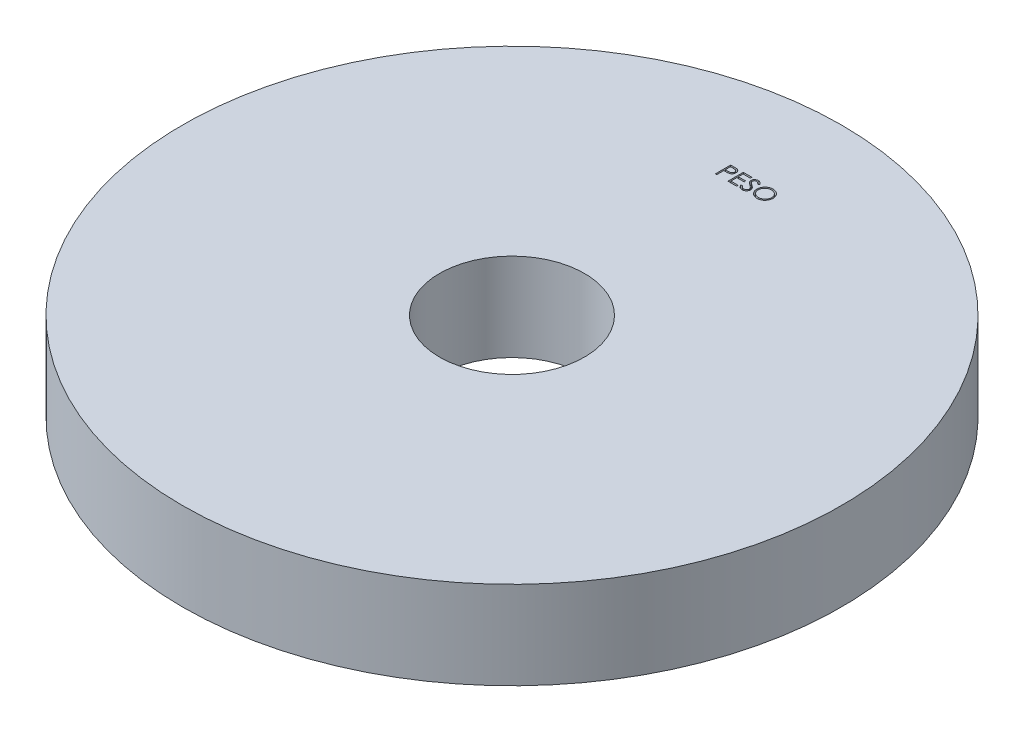
from build123d import *

# Parameters (mm, degrees)
ESBO_O1_R                = 75
ESBO_O1_R_2              = 16.5
RESSALTO_EXTRUS_O1_DEPTH = 20
CORTE_EXTRUS_O1_DEPTH    = 1


with BuildPart() as part:
    # Esboço1 → Ressalto-extrusão1 (new body)
    with BuildSketch(Plane(origin=(0, 0, 0), x_dir=(1, 0, 0), z_dir=(0, 1, 0))):
        Circle(ESBO_O1_R)
        Circle(ESBO_O1_R_2, mode=Mode.SUBTRACT)
    extrude(amount=RESSALTO_EXTRUS_O1_DEPTH)

    # Esboço2 → Corte-extrusão1 (cut)
    with BuildSketch(Plane(origin=(0, 20, 0), x_dir=(1, 0, 0), z_dir=(0, 1, 0))):
        with BuildLine():
            Line((-4.728102869, 54.494159365), (-4.041704632, 54.494159365))
            add(Edge.make_bspline(
                [(-4.041704632, 54.494159365), (-3.994493726, 54.494107469), (-3.904035533, 54.494008034), (-3.774320477, 54.490993288), (-3.656510746, 54.486966596), (-3.550860365, 54.481384703), (-3.457044267, 54.474788112), (-3.375486967, 54.465536073), (-3.305547411, 54.455875777), (-3.263640961, 54.446054371), (-3.244529151, 54.441575231)],
                knots=[0, 0, 0, 0, 0.000141628, 0.000271366, 0.00038923, 0.000495248, 0.00058876, 0.000671296, 0.000741499, 0.00080036, 0.00080036, 0.00080036, 0.00080036], degree=3))
            add(Edge.make_bspline(
                [(-3.244529151, 54.441575231), (-3.220335617, 54.434953281), (-3.17251864, 54.421865419), (-3.103617597, 54.395651696), (-3.038063752, 54.364569531), (-2.975632193, 54.329145591), (-2.91709011, 54.287860027), (-2.861564069, 54.242386409), (-2.809544089, 54.19167484), (-2.761322697, 54.1362941), (-2.717037899, 54.077173891), (-2.678908217, 54.013431661), (-2.64698099, 53.946140357), (-2.619597718, 53.875346786), (-2.599889264, 53.800456463), (-2.585042364, 53.72198975), (-2.575618736, 53.63995506), (-2.574716175, 53.583895192), (-2.574256715, 53.555357282)],
                knots=[0, 0, 0, 0, 7.5216e-05, 0.00014866, 0.000220794, 0.000292713, 0.000363707, 0.000435434, 0.000507823, 0.000581364, 0.000655543, 0.000729131, 0.000803767, 0.000878771, 0.000956497, 0.001035702, 0.001118238, 0.001203821, 0.001203821, 0.001203821, 0.001203821], degree=3))
            add(Edge.make_bspline(
                [(-2.574256715, 53.555357282), (-2.57467814, 53.526579505), (-2.575502686, 53.470273841), (-2.585398971, 53.387901053), (-2.598729163, 53.309182663), (-2.619226215, 53.234293213), (-2.646071888, 53.163677442), (-2.677563941, 53.09625621), (-2.715547472, 53.033176538), (-2.759192301, 52.974209421), (-2.807743896, 52.919299508), (-2.860996834, 52.868844714), (-2.918736126, 52.823140375), (-2.980778274, 52.782084032), (-3.047728123, 52.746627752), (-3.118570277, 52.714870447), (-3.193920493, 52.688199387), (-3.246063007, 52.674169325), (-3.272574023, 52.667035968)],
                knots=[0, 0, 0, 0, 8.6284e-05, 0.00016882, 0.000248587, 0.000325638, 0.000401297, 0.000474998, 0.000548586, 0.000621785, 0.0006948, 0.0007682, 0.000841564, 0.000915458, 0.000991056, 0.00106858, 0.00114819, 0.001230532, 0.001230532, 0.001230532, 0.001230532], degree=3))
            add(Edge.make_bspline(
                [(-3.272574023, 52.667035968), (-3.294501357, 52.662372987), (-3.342556384, 52.652153793), (-3.421699106, 52.640745336), (-3.513844492, 52.631007735), (-3.618866772, 52.623706598), (-3.736671677, 52.617456229), (-3.867322935, 52.612488135), (-4.011077012, 52.609758281), (-4.111348256, 52.609617489), (-4.163699824, 52.609543981)],
                knots=[0, 0, 0, 0, 6.7238e-05, 0.000147357, 0.000239727, 0.000345177, 0.000463135, 0.000593636, 0.000737393, 0.000894446, 0.000894446, 0.000894446, 0.000894446], degree=3))
            Line((-4.163699824, 52.609543981), (-4.414000305, 52.609543981))
            Line((-4.414000305, 52.609543981), (-4.414000305, 50.994159365))
            Line((-4.414000305, 50.994159365), (-4.728102869, 50.994159365))
            Line((-4.728102869, 50.994159365), (-4.728102869, 54.494159365))
        make_face()
        with BuildLine():
            Line((-4.414000305, 54.135185006), (-4.414000305, 52.96851834))
            Line((-4.414000305, 52.96851834), (-3.801219856, 52.960806))
            add(Edge.make_bspline(
                [(-3.801219856, 52.960806), (-3.77129993, 52.960790536), (-3.713540131, 52.960760684), (-3.630103907, 52.964745908), (-3.55269462, 52.96934644), (-3.481550045, 52.976082364), (-3.41663811, 52.985603621), (-3.357850581, 52.995215359), (-3.305643298, 53.009120722), (-3.244544097, 53.027843791), (-3.176460749, 53.059776407), (-3.102393201, 53.106126297), (-3.039622614, 53.165207005), (-2.985304317, 53.231634836), (-2.94219844, 53.305533966), (-2.910642447, 53.384602902), (-2.89210129, 53.468030752), (-2.889615096, 53.525118891), (-2.888359279, 53.553955039)],
                knots=[0, 0, 0, 0, 8.9746e-05, 0.000173253, 0.000250533, 0.00032239, 0.000387534, 0.00044736, 0.000500926, 0.000549486, 0.000638903, 0.000725641, 0.000810488, 0.000896226, 0.000982324, 0.00106604, 0.001150757, 0.001237226, 0.001237226, 0.001237226, 0.001237226], degree=3))
            add(Edge.make_bspline(
                [(-2.888359279, 53.553955039), (-2.889621926, 53.582093552), (-2.892131911, 53.638029434), (-2.910787774, 53.720008195), (-2.942137088, 53.798243899), (-2.985593682, 53.871216984), (-3.038334812, 53.937405788), (-3.099634155, 53.994902916), (-3.169347417, 54.041124618), (-3.234195648, 54.0709579), (-3.291796834, 54.089173175), (-3.341828794, 54.101918016), (-3.398319468, 54.112093622), (-3.461287248, 54.120333125), (-3.530244082, 54.127386586), (-3.605782396, 54.132172563), (-3.68761604, 54.13497402), (-3.744426611, 54.135112975), (-3.773876106, 54.135185006)],
                knots=[0, 0, 0, 0, 8.4371e-05, 0.000167719, 0.000250783, 0.000336277, 0.000421575, 0.000503926, 0.000587348, 0.000671427, 0.000717102, 0.000768457, 0.000826213, 0.000889178, 0.000958942, 0.001034123, 0.001116202, 0.001204546, 0.001204546, 0.001204546, 0.001204546], degree=3))
            Line((-3.773876106, 54.135185006), (-4.414000305, 54.135185006))
        make_face(mode=Mode.SUBTRACT)
        Polygon((-1.856307997, 54.494159365), (0.118050977, 54.494159365), (0.118050977, 54.135185006), (-1.542205433, 54.135185006), (-1.542205433, 53.05826193), (0.118050977, 53.05826193), (0.118050977, 52.699287571), (-1.542205433, 52.699287571), (-1.542205433, 51.353133724), (0.118050977, 51.353133724), (0.118050977, 50.994159365), (-1.856307997, 50.994159365), align=None)
        with BuildLine():
            Line((0.387281746, 51.669339654), (0.683155144, 51.846723468))
            add(Edge.make_bspline(
                [(0.683155144, 51.846723468), (0.710673381, 51.800659083), (0.763397262, 51.712401499), (0.851348621, 51.593143459), (0.942481532, 51.491781302), (1.037470865, 51.408904694), (1.135736814, 51.343655808), (1.237920867, 51.297453576), (1.343678678, 51.268637601), (1.4156525, 51.265137514), (1.451584631, 51.263390135)],
                knots=[0, 0, 0, 0, 0.000160901, 0.00030828, 0.000443778, 0.00056903, 0.000685513, 0.000796284, 0.00090427, 0.001011928, 0.001011928, 0.001011928, 0.001011928], degree=3))
            add(Edge.make_bspline(
                [(1.451584631, 51.263390135), (1.482271491, 51.264244807), (1.543108264, 51.265939197), (1.632670507, 51.282219999), (1.71965231, 51.307232128), (1.802260947, 51.34305306), (1.879356562, 51.386391546), (1.946963257, 51.438737723), (2.00540937, 51.497343929), (2.053218485, 51.562726584), (2.08989852, 51.633043732), (2.118090589, 51.705219683), (2.133735662, 51.780388252), (2.136092416, 51.830998715), (2.137281746, 51.856539173)],
                knots=[0, 0, 0, 0, 9.1978e-05, 0.000182347, 0.000272202, 0.000362975, 0.000451852, 0.000536835, 0.000618639, 0.000699414, 0.000778765, 0.000855983, 0.0009312, 0.001007828, 0.001007828, 0.001007828, 0.001007828], degree=3))
            add(Edge.make_bspline(
                [(2.137281746, 51.856539173), (2.135807436, 51.885680023), (2.132810377, 51.944919112), (2.107478897, 52.032318765), (2.06762965, 52.118811335), (2.030867007, 52.172312601), (2.011780945, 52.200088853)],
                knots=[0, 0, 0, 0, 8.7281e-05, 0.000177429, 0.000270909, 0.000371844, 0.000371844, 0.000371844, 0.000371844], degree=3))
            add(Edge.make_bspline(
                [(2.011780945, 52.200088853), (1.996110331, 52.220135676), (1.963211837, 52.262221475), (1.906654324, 52.32486671), (1.84028821, 52.389485129), (1.766384655, 52.458544186), (1.682251566, 52.528831983), (1.590524051, 52.603700261), (1.488860193, 52.680301838), (1.417560696, 52.731674403), (1.38077133, 52.758181801)],
                knots=[0, 0, 0, 0, 7.6319e-05, 0.000160223, 0.000252933, 0.000354147, 0.000463581, 0.000581729, 0.000709336, 0.000845369, 0.000845369, 0.000845369, 0.000845369], degree=3))
            add(Edge.make_bspline(
                [(1.38077133, 52.758181801), (1.343947333, 52.784410389), (1.273542657, 52.834557451), (1.175084075, 52.908981735), (1.087039612, 52.977025605), (1.009800595, 53.039329617), (0.943400998, 53.095902222), (0.887317587, 53.146200161), (0.84297903, 53.191583722), (0.818323449, 53.221025063), (0.807253701, 53.2342435)],
                knots=[0, 0, 0, 0, 0.000135623, 0.000259301, 0.000370234, 0.000469439, 0.00055697, 0.000631911, 0.000695377, 0.00074709, 0.00074709, 0.00074709, 0.00074709], degree=3))
            add(Edge.make_bspline(
                [(0.807253701, 53.2342435), (0.791781156, 53.254844537), (0.761352319, 53.295359241), (0.721186314, 53.358684098), (0.687047151, 53.423507364), (0.660284819, 53.490003228), (0.6377486, 53.557238157), (0.62259067, 53.626089403), (0.613099273, 53.696248021), (0.612127286, 53.743461522), (0.611640721, 53.767096064)],
                knots=[0, 0, 0, 0, 7.727e-05, 0.000151962, 0.000224716, 0.000296717, 0.00036678, 0.0004372, 0.000507902, 0.000578771, 0.000578771, 0.000578771, 0.000578771], degree=3))
            add(Edge.make_bspline(
                [(0.611640721, 53.767096064), (0.61294593, 53.804125839), (0.61552845, 53.877393902), (0.637368967, 53.984424733), (0.671841861, 54.08661115), (0.720136748, 54.182941484), (0.782394101, 54.270907465), (0.854440076, 54.351520952), (0.940251562, 54.419289534), (1.034404185, 54.478501592), (1.137460557, 54.524847518), (1.245451461, 54.559808498), (1.358548533, 54.579617755), (1.435151667, 54.58246052), (1.474020528, 54.583902955)],
                knots=[0, 0, 0, 0, 0.000110999, 0.000219625, 0.000326272, 0.00043382, 0.000541574, 0.000648775, 0.000756959, 0.000868438, 0.000981703, 0.00109501, 0.001208203, 0.0013248, 0.0013248, 0.0013248, 0.0013248], degree=3))
            add(Edge.make_bspline(
                [(1.474020528, 54.583902955), (1.515264629, 54.582480404), (1.59728598, 54.579651402), (1.717935196, 54.555053871), (1.834095912, 54.514353199), (1.927539177, 54.468164541), (2.000671939, 54.422033126), (2.056444671, 54.380013301), (2.112962122, 54.331638193), (2.170680177, 54.276778947), (2.228620836, 54.214932196), (2.287644289, 54.146521507), (2.347888557, 54.071964951), (2.386644418, 54.01874045), (2.406512516, 53.991455039)],
                knots=[0, 0, 0, 0, 0.000123638, 0.000245877, 0.000367608, 0.000492088, 0.000557638, 0.000626769, 0.000701372, 0.00078072, 0.000865532, 0.000955497, 0.001051745, 0.001152989, 0.001152989, 0.001152989, 0.001152989], degree=3))
            Line((2.406512516, 53.991455039), (2.122558189, 53.776210647))
            add(Edge.make_bspline(
                [(2.122558189, 53.776210647), (2.105412256, 53.798299338), (2.072393199, 53.840836991), (2.022263712, 53.900408307), (1.975015064, 53.954824786), (1.928464664, 54.002089914), (1.885071033, 54.044792048), (1.842953991, 54.081351804), (1.80271964, 54.1121274), (1.752002729, 54.14497096), (1.688285011, 54.177527463), (1.608300474, 54.205076541), (1.524714199, 54.221631603), (1.467784568, 54.223820491), (1.438964439, 54.224928596)],
                knots=[0, 0, 0, 0, 8.3877e-05, 0.000161528, 0.000233552, 0.000299993, 0.000360485, 0.000416152, 0.000467195, 0.000512312, 0.000597287, 0.000681099, 0.000765389, 0.000851809, 0.000851809, 0.000851809, 0.000851809], degree=3))
            add(Edge.make_bspline(
                [(1.438964439, 54.224928596), (1.402807916, 54.223716896), (1.333083469, 54.221380247), (1.234093233, 54.195860262), (1.144999308, 54.155678401), (1.068446743, 54.099363423), (1.004709766, 54.032642431), (0.958604307, 53.955863576), (0.930854142, 53.871081173), (0.927467863, 53.811939517), (0.925743285, 53.781819622)],
                knots=[0, 0, 0, 0, 0.000108248, 0.000208746, 0.00030443, 0.000399793, 0.000492054, 0.00057947, 0.000666386, 0.000756591, 0.000756591, 0.000756591, 0.000756591], degree=3))
            add(Edge.make_bspline(
                [(0.925743285, 53.781819622), (0.926136411, 53.763068143), (0.926923307, 53.725534524), (0.937898105, 53.670083102), (0.951997434, 53.614771763), (0.974340066, 53.55984918), (1.00518537, 53.504354821), (1.045690545, 53.447333083), (1.096703857, 53.388281374), (1.13578087, 53.349874001), (1.156412355, 53.329596064)],
                knots=[0, 0, 0, 0, 5.616e-05, 0.000112411, 0.000169046, 0.000227244, 0.000289691, 0.000359134, 0.000436702, 0.000523463, 0.000523463, 0.000523463, 0.000523463], degree=3))
            add(Edge.make_bspline(
                [(1.156412355, 53.329596064), (1.164073728, 53.322759038), (1.182275395, 53.30651583), (1.215551321, 53.279923549), (1.259494119, 53.247120777), (1.31295632, 53.206533461), (1.376923682, 53.159451998), (1.451403238, 53.106478386), (1.535564771, 53.045892927), (1.595286687, 53.003535387), (1.62686508, 52.981138532)],
                knots=[0, 0, 0, 0, 3.0802e-05, 7.3177e-05, 0.000127725, 0.000195314, 0.000274544, 0.000365991, 0.000469501, 0.000585644, 0.000585644, 0.000585644, 0.000585644], degree=3))
            add(Edge.make_bspline(
                [(1.62686508, 52.981138532), (1.664850993, 52.953497173), (1.738405449, 52.899973511), (1.843063029, 52.819557831), (1.937956837, 52.740910062), (2.023420041, 52.664532455), (2.100296949, 52.591004362), (2.16773467, 52.519441182), (2.22642035, 52.450355609), (2.289599569, 52.361783033), (2.354157388, 52.253001949), (2.409598896, 52.119723711), (2.444557243, 51.98592739), (2.449128759, 51.896000554), (2.45138431, 51.851631321)],
                knots=[0, 0, 0, 0, 0.000140932, 0.000272896, 0.000395881, 0.000510584, 0.000616697, 0.000714904, 0.000805482, 0.000888372, 0.001041088, 0.001183793, 0.001320341, 0.001453327, 0.001453327, 0.001453327, 0.001453327], degree=3))
            add(Edge.make_bspline(
                [(2.45138431, 51.851631321), (2.450727172, 51.820252955), (2.449425657, 51.758105572), (2.434464743, 51.666850495), (2.412545078, 51.578219625), (2.379507844, 51.493308513), (2.339184686, 51.41056375), (2.288018438, 51.33215585), (2.228710753, 51.256349451), (2.160676989, 51.18516596), (2.086231086, 51.119819764), (2.007547392, 51.061690702), (1.924497119, 51.013222379), (1.837530802, 50.973671537), (1.746628465, 50.942738019), (1.651820681, 50.92032515), (1.55295117, 50.906569439), (1.485750689, 50.905141678), (1.451584631, 50.904415776)],
                knots=[0, 0, 0, 0, 9.4044e-05, 0.000186263, 0.000276729, 0.000367488, 0.000459046, 0.000552398, 0.000647774, 0.000747454, 0.000847311, 0.000944634, 0.001040472, 0.001135227, 0.001230788, 0.001328063, 0.00142712, 0.00152957, 0.00152957, 0.00152957, 0.00152957], degree=3))
            add(Edge.make_bspline(
                [(1.451584631, 50.904415776), (1.425149288, 50.904926957), (1.372611528, 50.905942883), (1.294902046, 50.914924163), (1.218762457, 50.927631267), (1.145148175, 50.947805337), (1.073110763, 50.972282314), (1.002963529, 51.002420646), (0.934672475, 51.038537848), (0.867854892, 51.079832872), (0.802680717, 51.127890617), (0.739761249, 51.183864113), (0.677032064, 51.246209618), (0.616344668, 51.316620182), (0.556471523, 51.393958265), (0.498593114, 51.478947448), (0.441511396, 51.571124802), (0.405695928, 51.635989887), (0.387281746, 51.669339654)],
                knots=[0, 0, 0, 0, 7.9276e-05, 0.000157554, 0.000234438, 0.000310629, 0.000386236, 0.000462555, 0.000539392, 0.000617798, 0.000698008, 0.000781971, 0.000870217, 0.00096315, 0.001060616, 0.001163492, 0.001271478, 0.00138575, 0.00138575, 0.00138575, 0.00138575], degree=3))
        make_face()
        with BuildLine():
            add(Edge.make_bspline(
                [(4.807153541, 54.583902955), (4.871961647, 54.582261476), (4.999250114, 54.579037475), (5.186325012, 54.554358371), (5.364920107, 54.511662981), (5.536490246, 54.454799999), (5.698983222, 54.378945614), (5.853622115, 54.287260465), (6.000038989, 54.178784006), (6.13626037, 54.05435478), (6.260917321, 53.918971326), (6.370743207, 53.774493416), (6.462785501, 53.621794613), (6.538371288, 53.461333783), (6.597669897, 53.293473815), (6.638588941, 53.117319812), (6.664727091, 52.934013122), (6.667782869, 52.808986257), (6.669333028, 52.745561609)],
                knots=[0, 0, 0, 0, 0.000194393, 0.000381804, 0.00056479, 0.000744601, 0.000923091, 0.001101652, 0.001283106, 0.001468738, 0.001654324, 0.001834514, 0.002012231, 0.002188181, 0.002365797, 0.002545211, 0.002729936, 0.002920126, 0.002920126, 0.002920126, 0.002920126], degree=3))
            add(Edge.make_bspline(
                [(6.669333028, 52.745561609), (6.667783096, 52.682604163), (6.664727999, 52.558507742), (6.638559222, 52.376364298), (6.597518222, 52.201273602), (6.538921956, 52.033527949), (6.463696477, 51.872950385), (6.371041306, 51.719963431), (6.261900095, 51.574516933), (6.137693244, 51.438204268), (6.002292202, 51.313206797), (5.857061935, 51.204287921), (5.705268615, 51.110563797), (5.544958907, 51.035780123), (5.37825887, 50.976008202), (5.203676547, 50.935255572), (5.022029993, 50.908968529), (4.89815899, 50.905950013), (4.835198413, 50.904415776)],
                knots=[0, 0, 0, 0, 0.000188789, 0.000372126, 0.000550857, 0.00072758, 0.000904164, 0.001081881, 0.001263191, 0.001448823, 0.00163441, 0.001815159, 0.001992641, 0.002168591, 0.002344885, 0.002522934, 0.002705576, 0.002894365, 0.002894365, 0.002894365, 0.002894365], degree=3))
            add(Edge.make_bspline(
                [(4.835198413, 50.904415776), (4.771774094, 50.905965163), (4.646747878, 50.909019416), (4.463210843, 50.935200821), (4.286933099, 50.976142125), (4.118418748, 51.034651561), (3.957573818, 51.110268792), (3.804083735, 51.202473171), (3.658564588, 51.311880312), (3.522222842, 51.436046887), (3.397473643, 51.571218439), (3.288714268, 51.716052694), (3.196489154, 51.867708151), (3.121125822, 52.026605675), (3.061461363, 52.191977117), (3.020756544, 52.364925595), (2.994420592, 52.544465101), (2.991385746, 52.666707999), (2.989845849, 52.728734686)],
                knots=[0, 0, 0, 0, 0.00019019, 0.000374915, 0.000555011, 0.000732396, 0.00090898, 0.001087298, 0.001268608, 0.00145424, 0.001639827, 0.001819595, 0.001996712, 0.002171394, 0.002346367, 0.002523053, 0.002703612, 0.002889599, 0.002889599, 0.002889599, 0.002889599], degree=3))
            add(Edge.make_bspline(
                [(2.989845849, 52.728734686), (2.990380484, 52.770367355), (2.991443011, 52.853107479), (3.004234703, 52.975974079), (3.022796404, 53.096864737), (3.049398317, 53.215435684), (3.084189984, 53.331396669), (3.125242011, 53.445547432), (3.175381857, 53.556731156), (3.232062505, 53.665474547), (3.295324313, 53.770082453), (3.365200062, 53.868962036), (3.439235431, 53.962943033), (3.520398824, 54.049590037), (3.606015269, 54.131423693), (3.697473648, 54.20718641), (3.794215892, 54.277561361), (3.896658272, 54.340981703), (4.002276547, 54.398340837), (4.111153324, 54.447562688), (4.221809896, 54.48980875), (4.334764544, 54.524049575), (4.449717316, 54.551081611), (4.5669191, 54.569488965), (4.686276527, 54.582313282), (4.766687846, 54.583370784), (4.807153541, 54.583902955)],
                knots=[0, 0, 0, 0, 0.000124849, 0.000248123, 0.000370193, 0.00049164, 0.000612319, 0.000733199, 0.000855287, 0.000977905, 0.001100913, 0.001221706, 0.001340948, 0.001459521, 0.001577551, 0.001696047, 0.001815534, 0.001936153, 0.002057243, 0.002175846, 0.002294342, 0.002412335, 0.002529682, 0.00264829, 0.002768075, 0.00288942, 0.00288942, 0.00288942, 0.00288942], degree=3))
        make_face()
        with BuildLine():
            add(Edge.make_bspline(
                [(4.822578221, 54.224928596), (4.789363587, 54.224523706), (4.723251854, 54.223717796), (4.624967318, 54.213102081), (4.527975384, 54.197972192), (4.432256022, 54.176390671), (4.338209733, 54.146986618), (4.244959891, 54.11314571), (4.153356838, 54.071924619), (4.06370298, 54.025351915), (3.976787904, 53.973802994), (3.894775203, 53.916831227), (3.817452559, 53.855772673), (3.745009292, 53.790484836), (3.67765812, 53.720635234), (3.614073419, 53.647282798), (3.556803837, 53.568330907), (3.50431826, 53.4859205), (3.45735042, 53.400158919), (3.415585065, 53.311949056), (3.381421057, 53.220571369), (3.35355868, 53.127017212), (3.330458869, 53.031434752), (3.315824945, 52.933098903), (3.305092586, 52.832503791), (3.30433274, 52.764521937), (3.303948413, 52.73013693)],
                knots=[0, 0, 0, 0, 9.9599e-05, 0.000198245, 0.000296222, 0.00039402, 0.00049227, 0.000591646, 0.000691452, 0.000793368, 0.000894612, 0.000994383, 0.001092713, 0.00119001, 0.001286696, 0.001383657, 0.001480979, 0.001579008, 0.001676595, 0.001774142, 0.001871547, 0.001968922, 0.002066879, 0.00216624, 0.00226698, 0.002370083, 0.002370083, 0.002370083, 0.002370083], degree=3))
            add(Edge.make_bspline(
                [(3.303948413, 52.73013693), (3.305223275, 52.679574709), (3.307731323, 52.580103178), (3.329688893, 52.434335035), (3.363510867, 52.294246748), (3.413368234, 52.160604839), (3.475718848, 52.032260556), (3.552745739, 51.910352451), (3.644004824, 51.794847577), (3.747668351, 51.686552308), (3.860991057, 51.587706504), (3.981323787, 51.500943095), (4.107377395, 51.427532845), (4.239480598, 51.367727773), (4.376928137, 51.320338035), (4.520605688, 51.287859404), (4.669556147, 51.266483949), (4.771086802, 51.264431193), (4.822578221, 51.263390135)],
                knots=[0, 0, 0, 0, 0.000151605, 0.000298253, 0.000441263, 0.000583229, 0.000725274, 0.000868635, 0.001014928, 0.001166177, 0.001317744, 0.00146543, 0.001610576, 0.001754594, 0.001899821, 0.002045914, 0.002195936, 0.002350312, 0.002350312, 0.002350312, 0.002350312], degree=3))
            add(Edge.make_bspline(
                [(4.822578221, 51.263390135), (4.857187722, 51.263865639), (4.925828759, 51.264808707), (5.027924281, 51.274307384), (5.128180493, 51.289539253), (5.226456773, 51.311469909), (5.322641584, 51.338917115), (5.417136387, 51.371524843), (5.508934677, 51.412206047), (5.599194515, 51.457153999), (5.685590757, 51.508394156), (5.768066289, 51.563432306), (5.844542269, 51.624400926), (5.91693134, 51.688718739), (5.984559029, 51.757682587), (6.046968014, 51.831202809), (6.103948146, 51.909743466), (6.156413792, 51.992028872), (6.203217055, 52.078025124), (6.243996154, 52.166554802), (6.27859227, 52.257399912), (6.306520775, 52.350691483), (6.328406237, 52.446252332), (6.343486157, 52.54421041), (6.354034595, 52.644369753), (6.354829672, 52.712113609), (6.355230464, 52.746262731)],
                knots=[0, 0, 0, 0, 0.000103804, 0.000205874, 0.000307314, 0.000407849, 0.000507719, 0.000607281, 0.000707445, 0.000808723, 0.000909609, 0.001008589, 0.001105934, 0.001202762, 0.001298946, 0.001395452, 0.001491794, 0.001589823, 0.001688026, 0.001785277, 0.001882027, 0.001979402, 0.0020772, 0.002175869, 0.002276609, 0.002379011, 0.002379011, 0.002379011, 0.002379011], degree=3))
            add(Edge.make_bspline(
                [(6.355230464, 52.746262731), (6.354829351, 52.780178235), (6.35403367, 52.847455885), (6.343491195, 52.946916704), (6.328390305, 53.044169915), (6.306627597, 53.138833718), (6.278577443, 53.230932243), (6.243990113, 53.320378991), (6.203204813, 53.407507186), (6.156396589, 53.492101483), (6.103780765, 53.573276221), (6.046286522, 53.650878633), (5.982921174, 53.723451375), (5.915495149, 53.792786069), (5.842324264, 53.857403958), (5.76373997, 53.917326479), (5.680696292, 53.973999753), (5.592769056, 54.025125315), (5.502025103, 54.072339548), (5.408911145, 54.112790551), (5.314482045, 54.14716267), (5.218977933, 54.176479636), (5.121594954, 54.197887666), (5.022991126, 54.213115716), (4.923302867, 54.223714101), (4.856259647, 54.22452248), (4.822578221, 54.224928596)],
                knots=[0, 0, 0, 0, 0.000101701, 0.000201743, 0.00029972, 0.000396835, 0.000492868, 0.000588308, 0.000684288, 0.000781261, 0.000878109, 0.000974304, 0.001070733, 0.001166917, 0.001264269, 0.001363274, 0.001463228, 0.001565678, 0.001668217, 0.001769947, 0.001869982, 0.001969573, 0.002069423, 0.002168785, 0.002268827, 0.002369827, 0.002369827, 0.002369827, 0.002369827], degree=3))
        make_face(mode=Mode.SUBTRACT)
    extrude(amount=-CORTE_EXTRUS_O1_DEPTH, mode=Mode.SUBTRACT)


solid = part.part
